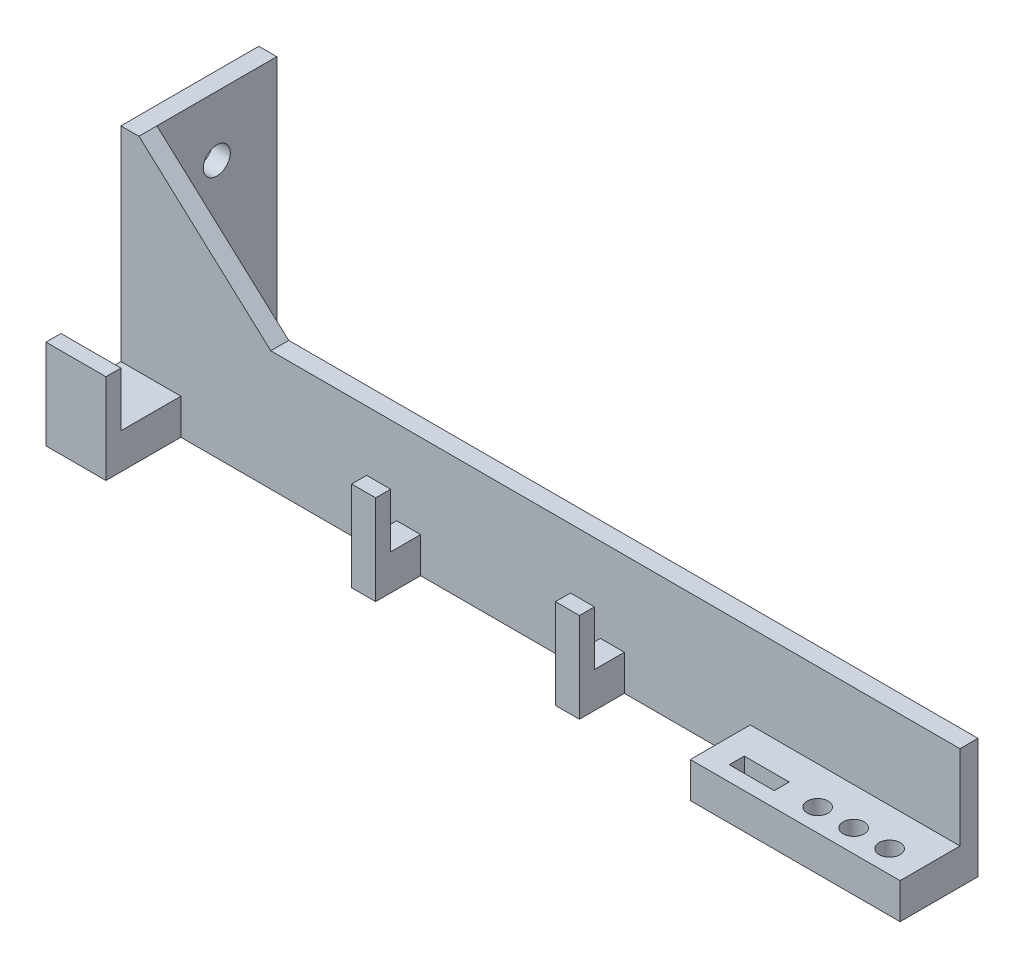
from build123d import *

# Parameters (mm, degrees)
SKETCH1_W           = 3
SKETCH1_H           = 20
BOSS_EXTRUDE1_DEPTH = 140
SKETCH3_W           = 10
SKETCH3_H           = 5.940571325
SKETCH3_W_2         = 4
SKETCH3_W_3         = 35
BOSS_EXTRUDE2_DEPTH = 10
SKETCH5_W           = 38
SKETCH5_H           = 5
CUT_EXTRUDE2_DEPTH  = 15
SKETCH6_W           = 10
SKETCH6_H           = 2.5
SKETCH6_W_2         = 4
BOSS_EXTRUDE4_DEPTH = 15
SKETCH7_R           = 1.75
SKETCH7_W           = 7.5
SKETCH7_H           = 2.5
CUT_EXTRUDE3_DEPTH  = 15
SKETCH9_W           = 20
SKETCH9_H           = 40
SKETCH9_R           = 2.25
BOSS_EXTRUDE5_DEPTH = 3
BOSS_EXTRUDE6_DEPTH = 3


with BuildPart() as part:
    # Sketch1 → Boss-Extrude1 (new body)
    with BuildSketch(Plane(origin=(0, 0, 0), x_dir=(0, 0, -1), z_dir=(1, 0, 0))):
        with Locations((1.5, -23)):
            Rectangle(SKETCH1_W, SKETCH1_H)
    extrude(amount=BOSS_EXTRUDE1_DEPTH)

    # Sketch3 → Boss-Extrude2 (add)
    with BuildSketch(Plane.XY):
        with Locations((5, -30.029714338)):
            Rectangle(SKETCH3_W, SKETCH3_H)
        with Locations((48, -30.029714338)):
            Rectangle(SKETCH3_W_2, SKETCH3_H)
        with Locations((82, -30.029714338)):
            Rectangle(SKETCH3_W_2, SKETCH3_H)
        with Locations((122.5, -30.029714338)):
            Rectangle(SKETCH3_W_3, SKETCH3_H)
    extrude(amount=BOSS_EXTRUDE2_DEPTH)

    # Sketch5 → Cut-Extrude2 (cut)
    with BuildSketch(Plane.XZ.offset(33)):
        with Locations((65, 7.5)):
            Rectangle(SKETCH5_W, SKETCH5_H)
    extrude(amount=-CUT_EXTRUDE2_DEPTH, mode=Mode.SUBTRACT)

    # Sketch6 → Boss-Extrude4 (add)
    with BuildSketch(Plane.XZ.offset(33)):
        with Locations((5, 11.25)):
            Rectangle(SKETCH6_W, SKETCH6_H)
        with Locations((48, 6.25)):
            Rectangle(SKETCH6_W_2, SKETCH6_H)
        with Locations((82, 6.25)):
            Rectangle(SKETCH6_W_2, SKETCH6_H)
    extrude(amount=-BOSS_EXTRUDE4_DEPTH)

    # Sketch7 → Cut-Extrude3 (cut)
    with BuildSketch(Plane(origin=(0, -27.059428675, 0), x_dir=(1, 0, 0), z_dir=(0, 1, 0))):
        with Locations((128.5, -6.25)):
            Circle(SKETCH7_R)
        with Locations((122.5, -6.25)):
            Circle(SKETCH7_R)
        with Locations((134.5, -6.25)):
            Circle(SKETCH7_R)
        with Locations((112.75, -6.25)):
            Rectangle(SKETCH7_W, SKETCH7_H)
    extrude(amount=-CUT_EXTRUDE3_DEPTH, mode=Mode.SUBTRACT)

    # Sketch9 → Boss-Extrude5 (add)
    with BuildSketch(Plane.ZY):
        with Locations((-13, -13)):
            Rectangle(SKETCH9_W, SKETCH9_H)
        with Locations((-13, -3)):
            Circle(SKETCH9_R, mode=Mode.SUBTRACT)
    extrude(amount=-BOSS_EXTRUDE5_DEPTH)

    # Sketch10 → Boss-Extrude6 (add)
    with BuildSketch(Plane.XY):
        Polygon((0, 7), (3, 7), (25, -13), (0, -13), align=None)
    extrude(amount=-BOSS_EXTRUDE6_DEPTH)


solid = part.part
